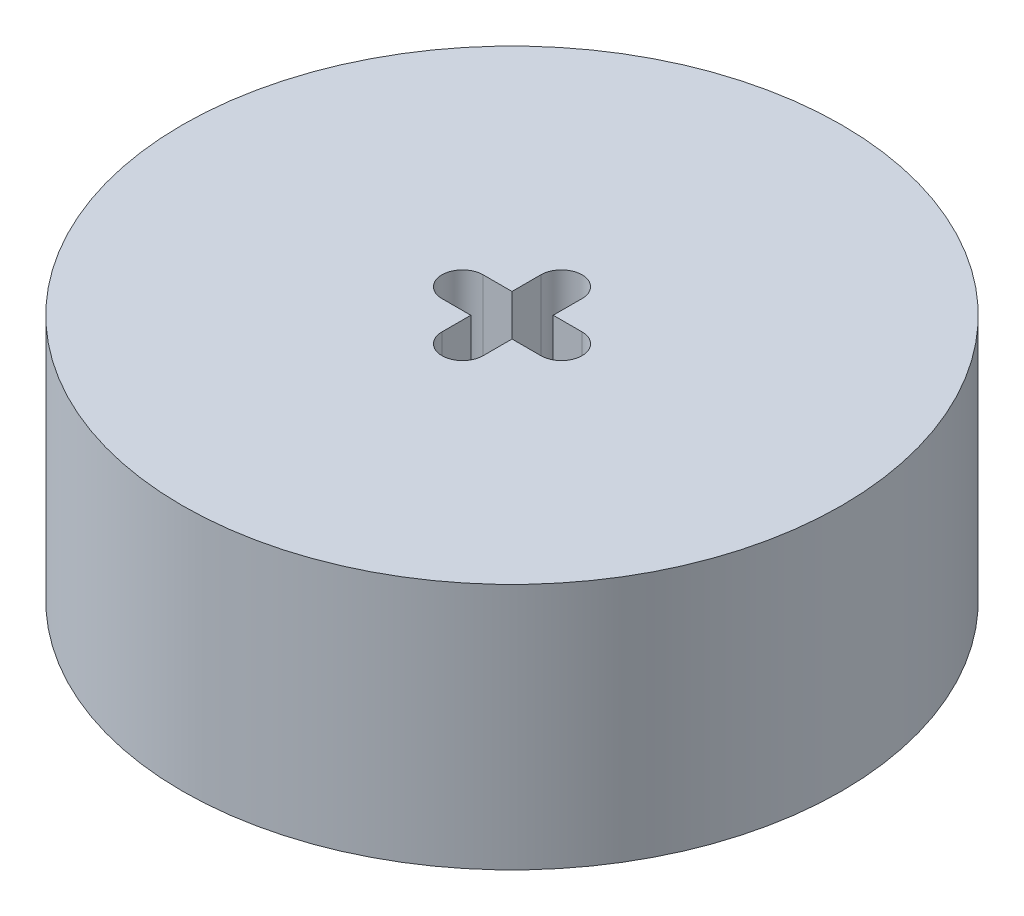
from build123d import *

# Parameters (mm, degrees)
SKETCH1_R           = 50.8
SKETCH1_R_2         = 3.175
BOSS_EXTRUDE1_DEPTH = 38.1
CUT_EXTRUDE1_DEPTH  = 39.1


with BuildPart() as part:
    # Sketch1 → Boss-Extrude1 (new body)
    with BuildSketch(Plane(origin=(0, 0, 0), x_dir=(1, 0, 0), z_dir=(0, 1, 0))):
        Circle(SKETCH1_R)
        Circle(SKETCH1_R_2, mode=Mode.SUBTRACT)
    extrude(amount=BOSS_EXTRUDE1_DEPTH)

    # Sketch2 → Cut-Extrude1 (cut, through all)
    with BuildSketch(Plane(origin=(0, 38.1, 0), x_dir=(1, 0, 0), z_dir=(0, 1, 0))):
        with BuildLine():
            Line((-3.175, 3.174), (-3.175, 7.620000001))
            ThreePointArc((-3.175, 7.620000001), (0, 10.795), (3.175, 7.62))
            Line((3.175, 7.62), (3.175, 3.176))
            Line((3.175, 3.176), (7.621, 3.176))
            ThreePointArc((7.621, 3.176), (10.796, 0.001), (7.621, -3.174))
            Line((7.621, -3.174), (3.177, -3.174))
            Line((3.177, -3.174), (3.177, -7.62))
            ThreePointArc((3.177, -7.62), (0.002, -10.795), (-3.173, -7.62))
            Line((-3.173, -7.62), (-3.173, -3.176))
            Line((-3.173, -3.176), (-7.619, -3.176))
            ThreePointArc((-7.619, -3.176), (-10.794, -0.001), (-7.619, 3.174))
            Line((-7.619, 3.174), (-3.175, 3.174))
        make_face()
    extrude(amount=-CUT_EXTRUDE1_DEPTH, mode=Mode.SUBTRACT)


solid = part.part
